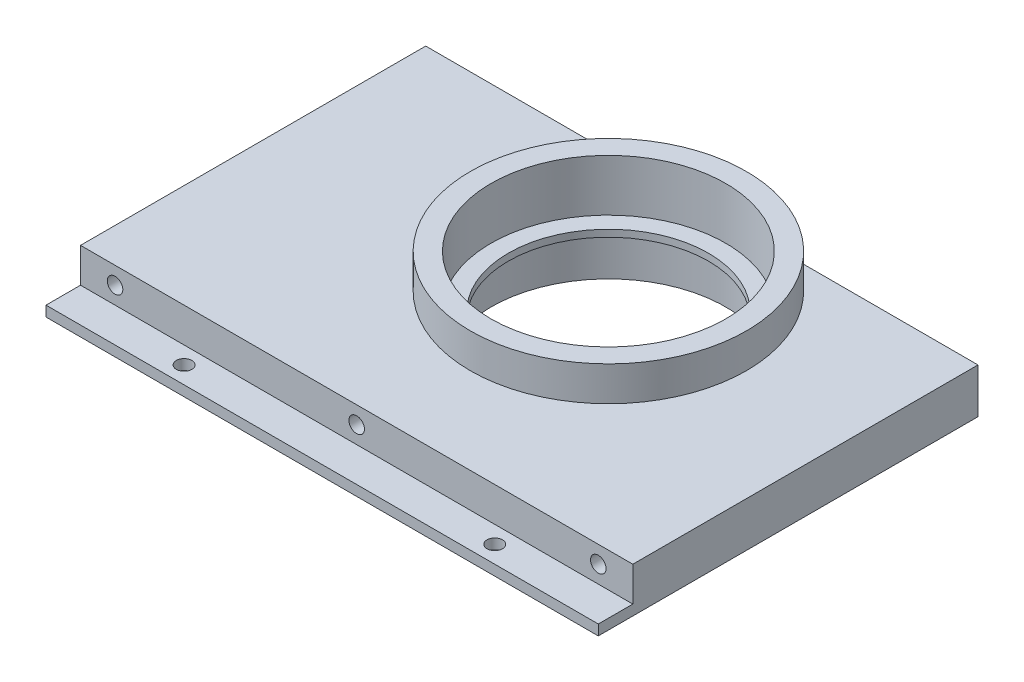
from build123d import *

# Parameters (mm, degrees)
SKETCH1_R                = 40
SKETCH1_R_2              = 34
BOSS_EXTRUDE1_DEPTH      = 15
SKETCH1_3_R              = 34
BOSS_EXTRUDE2_DEPTH      = 16
SKETCH1_4_R              = 34
SKETCH1_4_R_2            = 29
BOSS_EXTRUDE3_DEPTH      = 2
BOSS_EXTRUDE4_DEPTH      = 5
BOSS_EXTRUDE4_DEPTH_BACK = 5
SKETCH2_R                = 2.25
CUT_EXTRUDE1_DEPTH       = 10
BOSS_EXTRUDE5_START      = -10
BOSS_EXTRUDE5_DEPTH      = 3
SKETCH4_R                = 2.25
CUT_EXTRUDE3_DEPTH       = 3


with BuildPart() as part:
    # Sketch1 → Boss-Extrude1 (new body)
    with BuildSketch(Plane(origin=(0, 0, 0), x_dir=(1, 0, 0), z_dir=(0, 1, 0))):
        Circle(SKETCH1_R)
        Circle(SKETCH1_R_2, mode=Mode.SUBTRACT)
    extrude(amount=BOSS_EXTRUDE1_DEPTH)

    # Sketch1_3 → Boss-Extrude2 (add)
    with BuildSketch(Plane(origin=(0, 0, 0), x_dir=(1, 0, 0), z_dir=(0, 1, 0))):
        with BuildLine():
            ThreePointArc((19.364916731, 35), (0, 40), (-19.364916731, 35))
            ThreePointArc((-19.364916731, 35), (-20.315060063, -34.457195687), (40, 0))
            ThreePointArc((40, 0), (34.457195687, 20.315060063), (19.364916731, 35))
        make_face()
        Circle(SKETCH1_3_R, mode=Mode.SUBTRACT)
    extrude(amount=-BOSS_EXTRUDE2_DEPTH)

    # Sketch1_4 → Boss-Extrude3 (add)
    with BuildSketch(Plane(origin=(0, 0, 0), x_dir=(1, 0, 0), z_dir=(0, 1, 0))):
        Circle(SKETCH1_4_R)
        Circle(SKETCH1_4_R_2, mode=Mode.SUBTRACT)
    extrude(amount=-BOSS_EXTRUDE3_DEPTH)

    # Sketch1_5 → Boss-Extrude4 (add, two sides)
    with BuildSketch(Plane(origin=(0, 0, 0), x_dir=(1, 0, 0), z_dir=(0, 1, 0))) as boss_extrude4_sk:
        with BuildLine():
            Line((-19.364916731, 35), (-27.080992435, 35))
            Line((-27.080992435, 35), (-77.920992435, 35))
            Line((-77.920992435, 35), (-87.920992435, 35))
            Line((-87.920992435, 35), (-87.920992435, -65))
            Line((-87.920992435, -65), (-77.920992435, -65))
            Line((-77.920992435, -65), (0, -65))
            Line((0, -65), (72.08, -65))
            Line((72.08, -65), (72.08, 35))
            Line((72.08, 35), (37.080992435, 35))
            Line((37.080992435, 35), (19.364916731, 35))
            ThreePointArc((19.364916731, 35), (34.457195687, 20.315060063), (40, 0))
            ThreePointArc((40, 0), (-20.315060063, -34.457195687), (-19.364916731, 35))
        make_face()
    extrude(amount=BOSS_EXTRUDE4_DEPTH)
    extrude(boss_extrude4_sk.sketch, amount=-BOSS_EXTRUDE4_DEPTH_BACK)

    # Sketch2 → Cut-Extrude1 (cut)
    with BuildSketch(Plane.XY.offset(65)):
        with Locations((-77.920992435, 0)):
            Circle(SKETCH2_R)
        with Locations((-7.920496218, 0)):
            Circle(SKETCH2_R)
        with Locations((62.08, 0)):
            Circle(SKETCH2_R)
    extrude(amount=-CUT_EXTRUDE1_DEPTH, mode=Mode.SUBTRACT)

    # Sketch3 → Boss-Extrude5 (add)
    with BuildSketch(Plane(origin=(0, 5, 0), x_dir=(1, 0, 0), z_dir=(0, 1, 0)).offset(BOSS_EXTRUDE5_START)):
        with BuildLine():
            Line((19.364916731, 35), (62.079007565, 35))
            Line((62.079007565, 35), (72.08, 35))
            Line((72.08, 35), (72.08, -75))
            Line((72.08, -75), (62.079007565, -75))
            Line((62.079007565, -75), (-77.920992435, -75))
            Line((-77.920992435, -75), (-87.920992435, -75))
            Line((-87.920992435, -75), (-87.920992435, 35))
            Line((-87.920992435, 35), (-19.364916731, 35))
            ThreePointArc((-19.364916731, 35), (0, -40), (19.364916731, 35))
        make_face()
    extrude(amount=-BOSS_EXTRUDE5_DEPTH)

    # Sketch4 → Cut-Extrude3 (cut)
    with BuildSketch(Plane(origin=(0, -5, 0), x_dir=(-1, 0, 0), z_dir=(0, 1, 0))):
        with Locations((52.920992435, 70)):
            Circle(SKETCH4_R)
        with Locations((-37.08, 70)):
            Circle(SKETCH4_R)
    extrude(amount=-CUT_EXTRUDE3_DEPTH, mode=Mode.SUBTRACT)


solid = part.part
